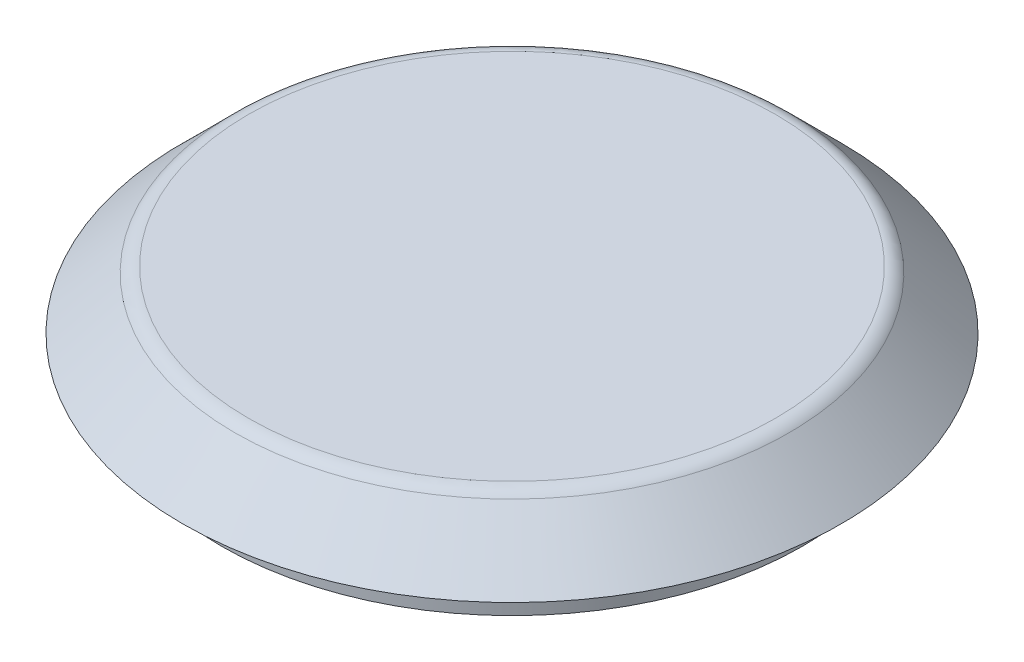
from build123d import *

# Parameters (mm, degrees)
SHELL1_T = -1


with BuildPart() as part:
    # Sketch2 → Revolve1 (revolve)
    with BuildSketch(Plane.XY, mode=Mode.PRIVATE) as revolve1_sk:
        with BuildLine():
            Line((15, 0), (15, 2))
            Line((15, 2), (17, 2))
            Line((17, 2), (14.292893219, 4.707106781))
            ThreePointArc((14.292893219, 4.707106781), (13.96846987, 4.923879533), (13.585786438, 5))
            Line((13.585786438, 5), (0, 5))
            Line((0, 5), (0, 0))
            Line((0, 0), (15, 0))
        make_face()
    revolve(revolve1_sk.sketch.rotate(Axis((0, 5, 0), (0, -1, 0)), 90), axis=Axis((0, 5, 0), (0, -1, 0)))

    # Shell1
    shell1_openings = [part.faces().sort_by_distance(p)[0] for p in [
        (0, 0, 0),
    ]]
    offset(amount=SHELL1_T, openings=shell1_openings, kind=Kind.INTERSECTION)


solid = part.part
